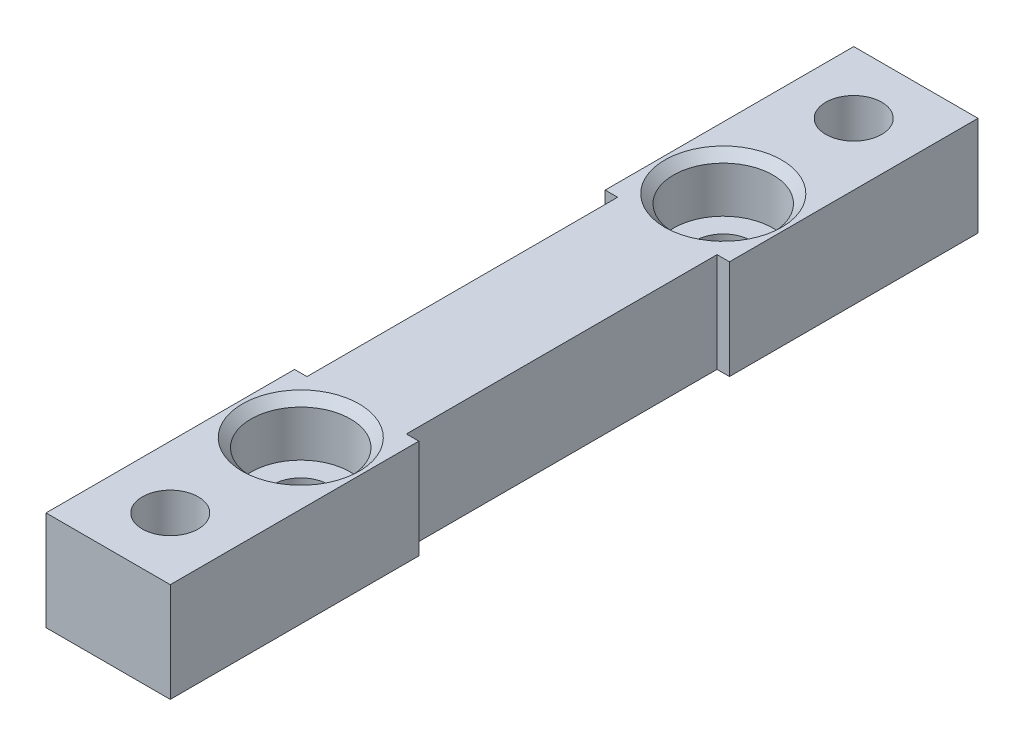
from build123d import *

# Parameters (mm, degrees)
SKETCH_1_W                  = 10
SKETCH_1_H                  = 20
SKETCH_1_W_2                = 8
SKETCH_1_H_2                = 25
EXTRUDE_1_DEPTH             = 8
HOLE_WIZARD_M4_1_AT_2_COUNT = 2
HOLE_WIZARD_M4_1_AT_2_PITCH = 34
HOLE_WIZARD_M4_1_2_D        = 4.5
HOLE_WIZARD_M4_1_2_DEPTH    = 8
SKETCH_7_R                  = 2.25
CUT_EXTRUDE_1_DEPTH         = 4


with BuildPart() as part:
    # 스케치1 → 보스-돌출1 (new body)
    with BuildSketch(Plane(origin=(0, 0, 0), x_dir=(1, 0, 0), z_dir=(0, 1, 0))):
        with Locations((0, 22.5)):
            Rectangle(SKETCH_1_W, SKETCH_1_H)
        Rectangle(SKETCH_1_W_2, SKETCH_1_H_2)
        with Locations((0, -22.5)):
            Rectangle(SKETCH_1_W, SKETCH_1_H)
    extrude(amount=EXTRUDE_1_DEPTH)

    # 스케치3 → Hole Wizard M4 _ _ _ _ _ _1 (revolve, cut)
    with BuildSketch(Plane(origin=(0, 8, -17), x_dir=(0, 0, 1), z_dir=(1, 0, 0))):
        Polygon((0, 0), (0, 8), (2.25, 8), (2.25, 4.4), (4, 4.4), (4, 0.7), (4.7, 0), align=None)
    hole_wizard_m4_1 = revolve(axis=Axis((0, 14.35, -17), (0, -1, 0)), mode=Mode.SUBTRACT)

    # Hole Wizard M4 _ _ _ _ _ _1 at 2: Hole Wizard M4 _ _ _ _ _ _1 ×2
    with Locations(*[(0, 0, i * HOLE_WIZARD_M4_1_AT_2_PITCH) for i in range(1, HOLE_WIZARD_M4_1_AT_2_COUNT)]):
        add(hole_wizard_m4_1, mode=Mode.SUBTRACT)

    # Hole Wizard M4 _ _1 2
    with Locations(Plane(origin=(0, 0, 0), x_dir=(-1, 0, 0), z_dir=(0, -1, 0))):
        with Locations((0, -27.5), (0, 27.5), (54.10839937, -109.42081154)):
            Hole(HOLE_WIZARD_M4_1_2_D / 2, depth=HOLE_WIZARD_M4_1_2_DEPTH)

    # 스케치7 → 컷-돌출1 (cut)
    with BuildSketch(Plane.XZ):
        Polygon((2.049593456, -31.05), (4.099186911, -27.5), (2.049593456, -23.95), (-2.049593456, -23.95), (-4.099186911, -27.5), (-2.049593456, -31.05), align=None)
        with Locations((0, -27.5)):
            Circle(SKETCH_7_R, mode=Mode.SUBTRACT)
        Polygon((2.049593456, 23.95), (-2.049593456, 23.95), (-4.099186911, 27.5), (-2.049593456, 31.05), (2.049593456, 31.05), (4.099186911, 27.5), align=None)
        with Locations((0, 27.5)):
            Circle(SKETCH_7_R, mode=Mode.SUBTRACT)
    extrude(amount=-CUT_EXTRUDE_1_DEPTH, mode=Mode.SUBTRACT)


solid = part.part
